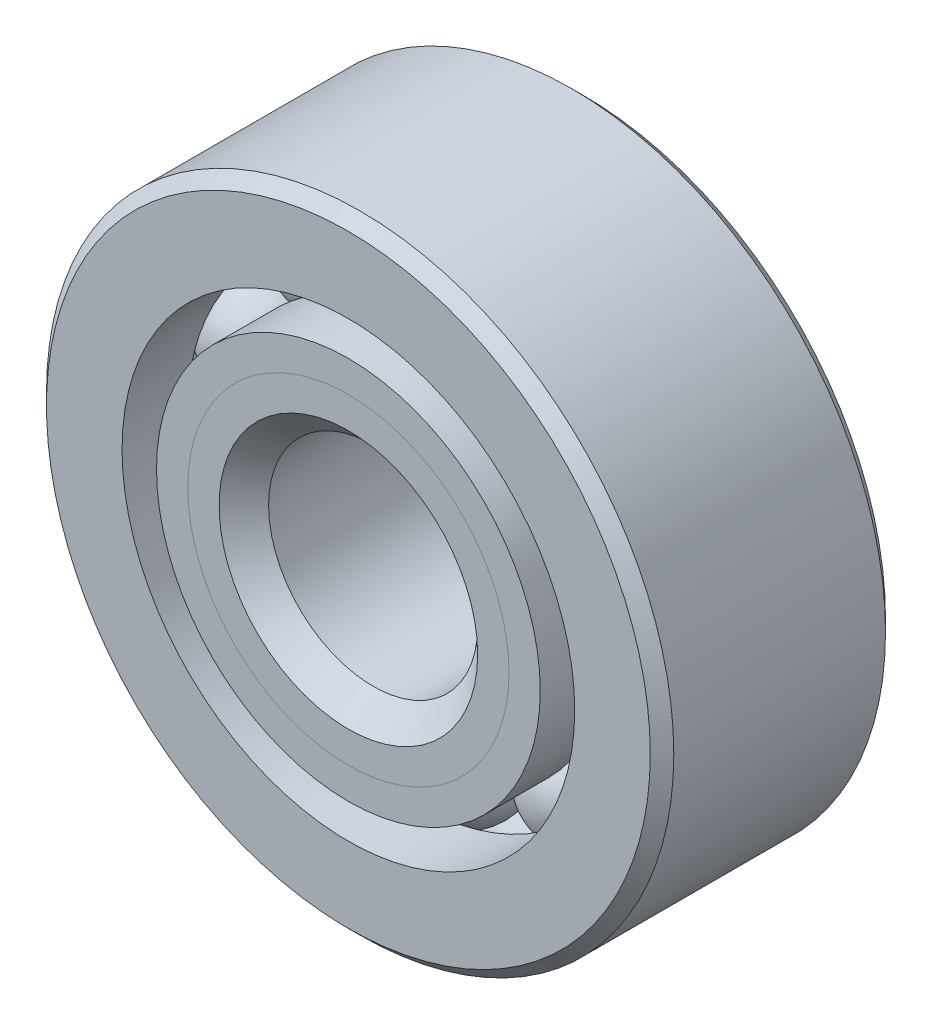
from build123d import *

# Parameters (mm, degrees)
CIRPATTERN1_COUNT = 10


with BuildPart() as part:
    # Sketch1 → Revolve1 (revolve)
    with BuildSketch(Plane(origin=(0, 0, 0), x_dir=(0, 0, -1), z_dir=(1, 0, 0))):
        with BuildLine():
            Line((3.2146875, 9.525), (-3.2146875, 9.525))
            Line((-3.2146875, 9.525), (-3.571875, 9.1678125))
            Line((-3.571875, 9.1678125), (-3.571875, 6.873351648))
            Line((-3.571875, 6.873351648), (-1.5875, 6.873351648))
            ThreePointArc((-1.5875, 6.873351648), (0, 8.021542162), (1.5875, 6.873351648))
            Line((1.5875, 6.873351648), (3.571875, 6.873351648))
            Line((3.571875, 6.873351648), (3.571875, 9.1678125))
            Line((3.571875, 9.1678125), (3.2146875, 9.525))
        make_face()
    revolve(axis=Axis((0, 0, 3.571875), (0, 0, -1)))


with BuildPart() as body_2:
    # Sketch2 → Revolve2 (revolve)
    with BuildSketch(Plane(origin=(0, 0, 0), x_dir=(0, 0, -1), z_dir=(1, 0, 0))):
        with BuildLine():
            Line((-3.571875, 5.826648352), (-1.5875, 5.826648352))
            ThreePointArc((-1.5875, 5.826648352), (-0.979604219, 4.995589142), (0, 4.678457838))
            Line((0, 4.678457838), (0, 3.926728919))
            Line((0, 3.926728919), (-2.621915284, 3.926728919))
            Line((-2.621915284, 3.926728919), (-3.571875, 4.876688635))
            Line((-3.571875, 4.876688635), (-3.571875, 5.826648352))
        make_face()
    revolve(axis=Axis((0, 0, 3.571875), (0, 0, -1)))


with BuildPart() as body_3:
    # Sketch3 → Revolve3 (revolve)
    with BuildSketch(Plane(origin=(0, 0, 0), x_dir=(0, 0, -1), z_dir=(1, 0, 0))):
        with BuildLine():
            Line((-3.571875, 4.876688635), (-2.621915284, 3.926728919))
            Line((-2.621915284, 3.926728919), (0, 3.926728919))
            Line((0, 3.926728919), (0, 4.678457838))
            ThreePointArc((0, 4.678457838), (0.979604219, 4.995589142), (1.5875, 5.826648352))
            Line((1.5875, 5.826648352), (3.571875, 5.826648352))
            Line((3.571875, 5.826648352), (3.571875, 3.5321875))
            Line((3.571875, 3.5321875), (3.2146875, 3.175))
            Line((3.2146875, 3.175), (-2.820146081, 3.175))
            Line((-2.820146081, 3.175), (-3.571875, 3.926728919))
            Line((-3.571875, 3.926728919), (-3.571875, 4.876688635))
        make_face()
    revolve(axis=Axis((0, 0, 3.571875), (0, 0, -1)))


with BuildPart() as body_4:
    # Sketch4 → Revolve4 (revolve)
    with BuildSketch(Plane(origin=(0, 0, 0), x_dir=(0, 0, -1), z_dir=(1, 0, 0))):
        with BuildLine():
            Line((-1.671542162, 6.35), (1.671542162, 6.35))
            ThreePointArc((1.671542162, 6.35), (0, 8.021542162), (-1.671542162, 6.35))
        make_face()
    revolve(axis=Axis((0, 6.35, 1.671542162), (0, 0, -1)))


with BuildPart() as cirpattern1_1:
    # CirPattern1: pattern copy
    add(body_4.part.rotate(Axis((0, 0, -3.571875), (0, 0, 1)), 1 * 360 / CIRPATTERN1_COUNT))


with BuildPart() as cirpattern1_2:
    # CirPattern1: pattern copy
    add(body_4.part.rotate(Axis((0, 0, -3.571875), (0, 0, 1)), 2 * 360 / CIRPATTERN1_COUNT))


with BuildPart() as cirpattern1_3:
    # CirPattern1: pattern copy
    add(body_4.part.rotate(Axis((0, 0, -3.571875), (0, 0, 1)), 3 * 360 / CIRPATTERN1_COUNT))


with BuildPart() as cirpattern1_4:
    # CirPattern1: pattern copy
    add(body_4.part.rotate(Axis((0, 0, -3.571875), (0, 0, 1)), 4 * 360 / CIRPATTERN1_COUNT))


with BuildPart() as cirpattern1_5:
    # CirPattern1: pattern copy
    add(body_4.part.rotate(Axis((0, 0, -3.571875), (0, 0, 1)), 5 * 360 / CIRPATTERN1_COUNT))


with BuildPart() as cirpattern1_6:
    # CirPattern1: pattern copy
    add(body_4.part.rotate(Axis((0, 0, -3.571875), (0, 0, 1)), 6 * 360 / CIRPATTERN1_COUNT))


with BuildPart() as cirpattern1_7:
    # CirPattern1: pattern copy
    add(body_4.part.rotate(Axis((0, 0, -3.571875), (0, 0, 1)), 7 * 360 / CIRPATTERN1_COUNT))


with BuildPart() as cirpattern1_8:
    # CirPattern1: pattern copy
    add(body_4.part.rotate(Axis((0, 0, -3.571875), (0, 0, 1)), 8 * 360 / CIRPATTERN1_COUNT))


with BuildPart() as cirpattern1_9:
    # CirPattern1: pattern copy
    add(body_4.part.rotate(Axis((0, 0, -3.571875), (0, 0, 1)), 9 * 360 / CIRPATTERN1_COUNT))


solid = Compound([part.part, body_2.part, body_3.part, body_4.part, cirpattern1_1.part, cirpattern1_2.part, cirpattern1_3.part, cirpattern1_4.part, cirpattern1_5.part, cirpattern1_6.part, cirpattern1_7.part, cirpattern1_8.part, cirpattern1_9.part])
